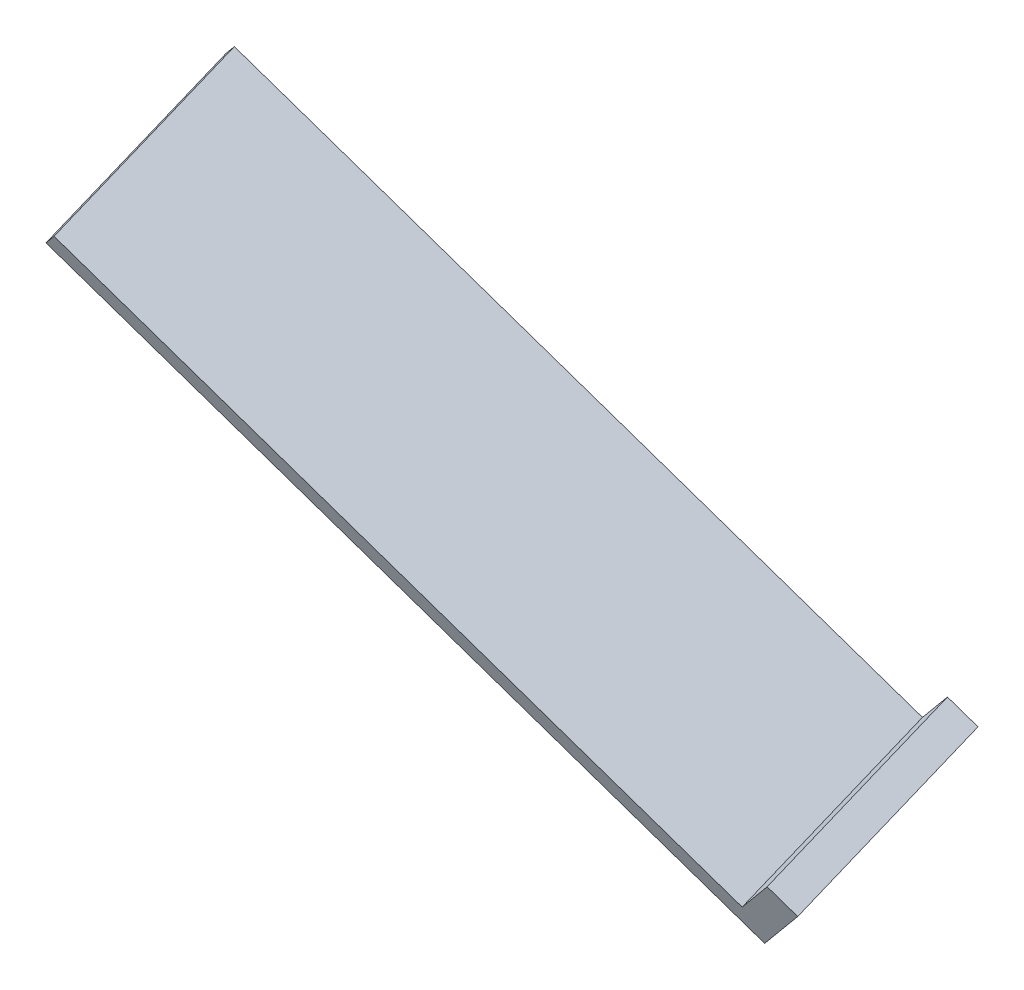
from build123d import *

# Parameters (mm, degrees)
SALIENTE_EXTRUIR1_START = 3.1
SALIENTE_EXTRUIR1_DEPTH = 1
SALIENTE_EXTRUIR2_START = -1
CROQUIS4_W              = 1.301297423
CROQUIS4_H              = 8.40000117
SALIENTE_EXTRUIR2_DEPTH = 4.1


with BuildPart() as part:
    # Croquis3 → Saliente-Extruir1 (new body)
    with BuildSketch(Plane(origin=(-33.880247059, -37.627827516, -15.480136045), x_dir=(-0.768464217, 0.591770514, 0.243455141), z_dir=(-0.639892762, -0.710672931, -0.292371747)).offset(SALIENTE_EXTRUIR1_START)):
        Polygon((-24.387334523, -104.987555147), (-25.688631315, -104.987555147), (-53.688631947, -104.987557356), (-53.688631947, -96.587556289), (-25.688631947, -96.587556289), (-24.387335186, -96.587556289), align=None)
    extrude(amount=SALIENTE_EXTRUIR1_DEPTH)

    # Croquis4 → Saliente-Extruir2 (add)
    with BuildSketch(Plane(origin=(-35.863914621, -39.830913602, -16.38648846), x_dir=(0.768464217, -0.591770514, -0.243455141), z_dir=(0.639892762, 0.710672931, 0.292371747)).offset(SALIENTE_EXTRUIR2_START)):
        with Locations((54.339280659, -100.787556874)):
            Rectangle(CROQUIS4_W, CROQUIS4_H)
    extrude(amount=SALIENTE_EXTRUIR2_DEPTH)


solid = part.part
